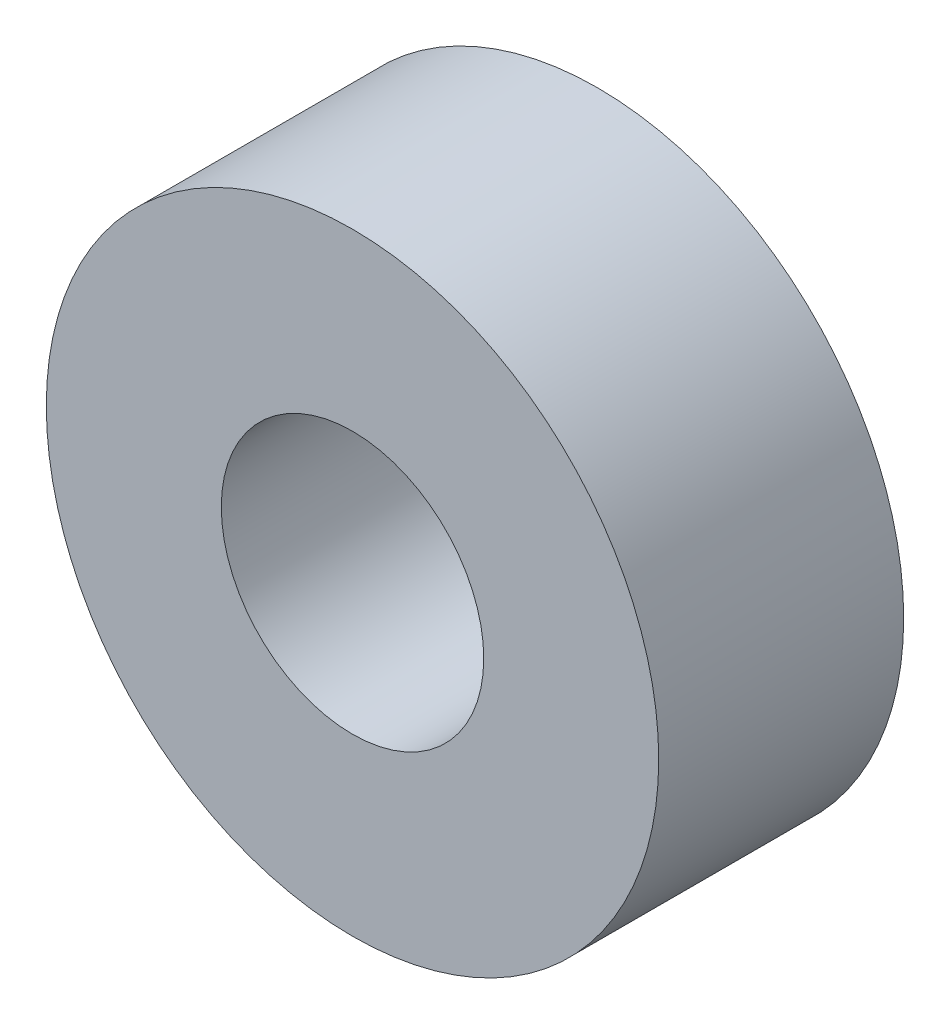
from build123d import *

# Parameters (mm, degrees)
CROQUIS1_R              = 17.5
CROQUIS1_R_2            = 7.5
SALIENTE_EXTRUIR1_DEPTH = 14


with BuildPart() as part:
    # Croquis1 → Saliente-Extruir1 (new body)
    with BuildSketch(Plane.XY):
        Circle(CROQUIS1_R)
        Circle(CROQUIS1_R_2, mode=Mode.SUBTRACT)
    extrude(amount=SALIENTE_EXTRUIR1_DEPTH)


solid = part.part
